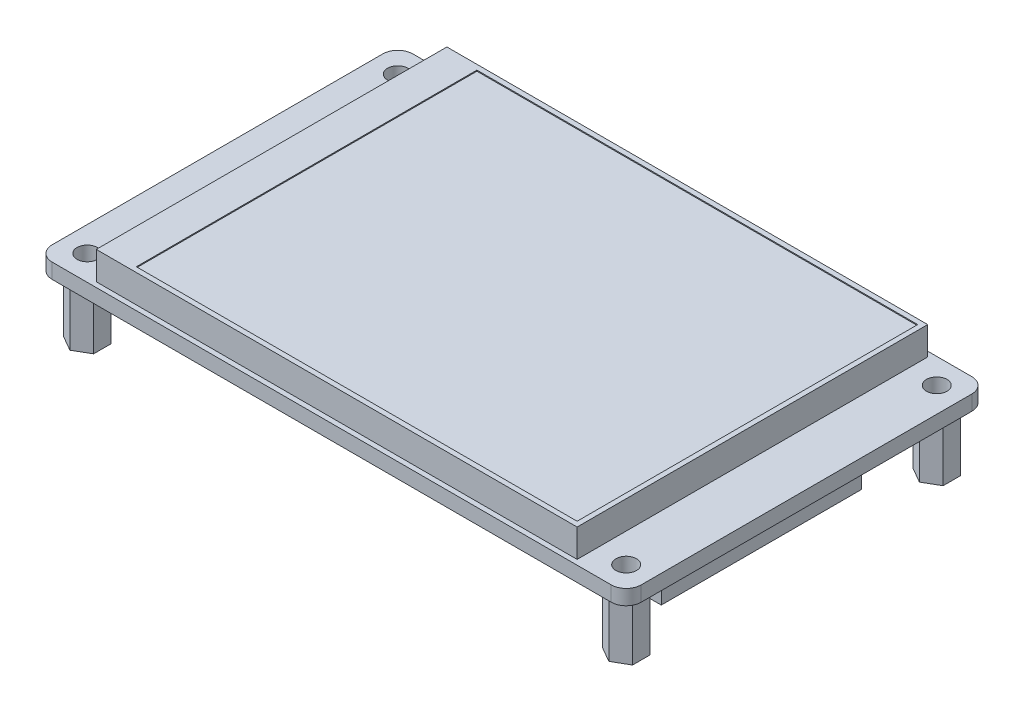
from build123d import *

# Parameters (mm, degrees)
SKETCH1_W                          = 58.8
SKETCH1_H                          = 36
BOSS_EXTRUDE1_DEPTH                = 1.5
SKETCH1_3_W                        = 48
SKETCH1_3_H                        = 35
BOSS_EXTRUDE2_DEPTH                = 2.8
FILLET1_R                          = 1.5
BOSS_EXTRUDE3_START                = -1.5
BOSS_EXTRUDE3_DEPTH                = 6
M2_5X0_45_TAPPED_HOLE1_D           = 2.05
M2_5X0_45_TAPPED_HOLE1_CSINK_D     = 2.55
M2_5X0_45_TAPPED_HOLE1_CSINK_ANGLE = 60
SKETCH5_W                          = 44
SKETCH5_H                          = 34
CUT_EXTRUDE2_DEPTH                 = 0.1
MIRROR3_START                      = -1.5
MIRROR3_COPY_1_DEPTH               = 6
MIRROR3_COPY_2_D                   = 2.05
MIRROR3_COPY_2_CSINK_D             = 2.55
MIRROR3_COPY_2_CSINK_ANGLE         = 60
SKETCH9_W                          = 6
SKETCH9_H                          = 20
BOSS_EXTRUDE4_DEPTH                = 5.75


with BuildPart() as part:
    # Sketch1 → Boss-Extrude1 (new body)
    with BuildSketch(Plane(origin=(0, 0, 0), x_dir=(1, 0, 0), z_dir=(0, 1, 0))):
        Rectangle(SKETCH1_W, SKETCH1_H)
    extrude(amount=-BOSS_EXTRUDE1_DEPTH)

    # Sketch1_3 → Boss-Extrude2 (add)
    with BuildSketch(Plane(origin=(0, 0, 0), x_dir=(1, 0, 0), z_dir=(0, 1, 0))):
        Rectangle(SKETCH1_3_W, SKETCH1_3_H)
    extrude(amount=BOSS_EXTRUDE2_DEPTH)

    # Fillet1
    fillet1_edges = [part.edges().sort_by_distance(p)[0] for p in [
        (-29.4, -0.75, 18),
        (-29.4, -0.75, -18),
        (29.4, -0.75, -18),
        (29.4, -0.75, 18),
    ]]
    fillet(fillet1_edges, radius=FILLET1_R)

    # Sketch3 → Boss-Extrude3 (add)
    with BuildSketch(Plane(origin=(0, 0, 0), x_dir=(1, 0, 0), z_dir=(0, 1, 0)).offset(BOSS_EXTRUDE3_START)):
        Polygon((-26.9, 17.232050808), (-28.4, 16.366025404), (-28.4, 14.633974596), (-26.9, 13.767949192), (-25.4, 14.633974596), (-25.4, 16.366025404), align=None)
    boss_extrude3 = extrude(amount=-BOSS_EXTRUDE3_DEPTH)

    # M2.5x0.45 Tapped Hole1 (through all)
    with Locations(Plane(origin=(0, -7.5, 0), x_dir=(-1, 0, 0), z_dir=(0, -1, 0))):
        with Locations((26.9, 15.5)):
            m2_5x0_45_tapped_hole1 = CounterSinkHole(M2_5X0_45_TAPPED_HOLE1_D / 2, M2_5X0_45_TAPPED_HOLE1_CSINK_D / 2, counter_sink_angle=M2_5X0_45_TAPPED_HOLE1_CSINK_ANGLE)

    # Sketch5 → Cut-Extrude2 (cut)
    with BuildSketch(Plane(origin=(0, 2.8, 0), x_dir=(1, 0, 0), z_dir=(0, 1, 0))):
        with Locations((1.5, 0)):
            Rectangle(SKETCH5_W, SKETCH5_H)
    extrude(amount=-CUT_EXTRUDE2_DEPTH, mode=Mode.SUBTRACT)

    # Mirror2: Boss-Extrude3, M2.5x0.45 Tapped Hole1 across plane
    add(boss_extrude3.mirror(Plane.XY))
    add(m2_5x0_45_tapped_hole1.mirror(Plane.XY), mode=Mode.SUBTRACT)

    # Mirror3: Boss-Extrude3, M2.5x0.45 Tapped Hole1 across plane
    add(boss_extrude3.mirror(Plane(origin=(0, 0, 0), x_dir=(0, 0, 1), z_dir=(1, 0, 0))))
    add(m2_5x0_45_tapped_hole1.mirror(Plane(origin=(0, 0, 0), x_dir=(0, 0, 1), z_dir=(1, 0, 0))), mode=Mode.SUBTRACT)

    # Mirror3 copy 1 sketch → Mirror3 copy 1 (add)
    with BuildSketch(Plane(origin=(0, 0, 0), x_dir=(-1, 0, 0), z_dir=(0, 1, 0)).offset(MIRROR3_START)):
        Polygon((-26.9, 17.232050808), (-28.4, 16.366025404), (-28.4, 14.633974596), (-26.9, 13.767949192), (-25.4, 14.633974596), (-25.4, 16.366025404), align=None)
    extrude(amount=-MIRROR3_COPY_1_DEPTH)

    # Mirror3 copy 2 (through all)
    with Locations(Plane.XZ.offset(7.5)):
        with Locations((26.9, 15.5)):
            CounterSinkHole(MIRROR3_COPY_2_D / 2, MIRROR3_COPY_2_CSINK_D / 2, counter_sink_angle=MIRROR3_COPY_2_CSINK_ANGLE)

    # Sketch9 → Boss-Extrude4 (add)
    with BuildSketch(Plane.XZ.offset(1.5)):
        with Locations((21.9, 0)):
            Rectangle(SKETCH9_W, SKETCH9_H)
    extrude(amount=BOSS_EXTRUDE4_DEPTH)


solid = part.part
